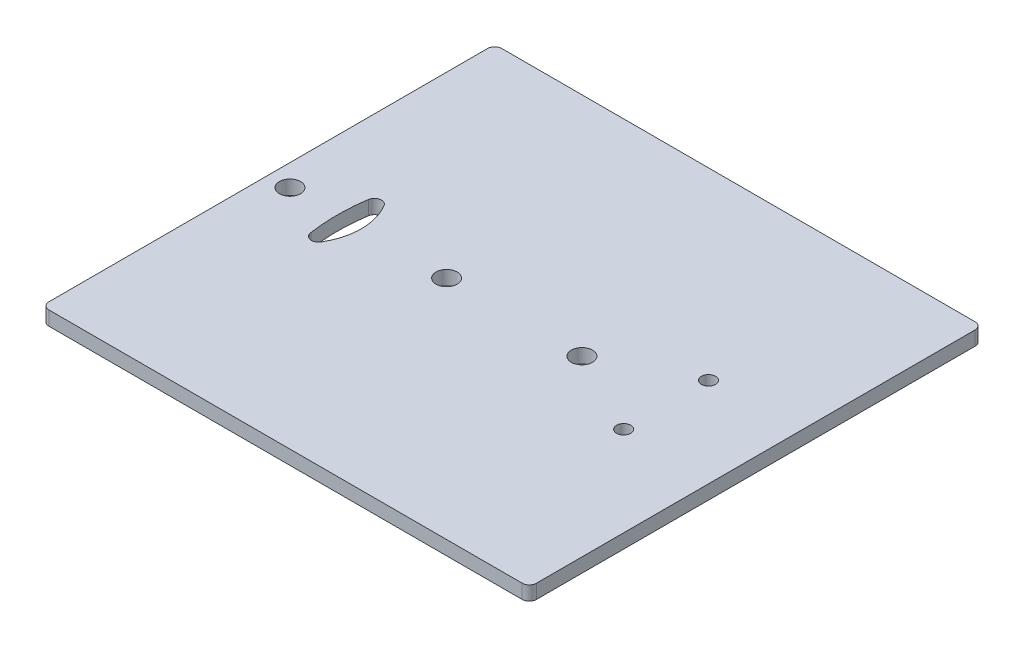
from build123d import *

# Parameters (mm, degrees)
CROQUIS1_W              = 69
CROQUIS1_H              = 64.099232263
CROQUIS1_R              = 1
CROQUIS1_R_2            = 1.5
SALIENTE_EXTRUIR1_DEPTH = 2
REDONDEO1_R             = 1


with BuildPart() as part:
    # Croquis1 → Saliente-Extruir1 (new body)
    with BuildSketch(Plane(origin=(0, 0, 0), x_dir=(1, 0, 0), z_dir=(0, 1, 0))):
        with Locations((-35.029110392, 0.70962906)):
            Rectangle(CROQUIS1_W, CROQUIS1_H)
        with BuildLine():
            ThreePointArc((-59.454384172, 4.810651437), (-58.662459069, 5.641041677), (-57.611472837, 5.180475439))
            ThreePointArc((-57.611472837, 5.180475439), (-56.358108465, 0.762709988), (-57.556841461, -3.67019121))
            ThreePointArc((-57.556841461, -3.67019121), (-57.60722938, -3.763799887), (-57.667223738, -3.851562088))
            ThreePointArc((-57.667223738, -3.851562088), (-58.665645829, -4.226208068), (-59.438939328, -3.491889713))
            ThreePointArc((-59.438939328, -3.491889713), (-59.459295474, -3.392138765), (-59.469455013, -3.290840157))
            ThreePointArc((-59.469455013, -3.290840157), (-59.763795222, 0.760467206), (-59.454384172, 4.810651437))
        make_face(mode=Mode.SUBTRACT)
        with Locations((-13.221985845, -5.290370941)):
            Circle(CROQUIS1_R, mode=Mode.SUBTRACT)
        with Locations((-66.45759178, 0.709629059)):
            Circle(CROQUIS1_R_2, mode=Mode.SUBTRACT)
        with Locations((-44.286593268, 0.709629059)):
            Circle(CROQUIS1_R_2, mode=Mode.SUBTRACT)
        with Locations((-25.130085357, 0.709629059)):
            Circle(CROQUIS1_R_2, mode=Mode.SUBTRACT)
        with Locations((-13.221985845, 6.709629059)):
            Circle(CROQUIS1_R, mode=Mode.SUBTRACT)
    extrude(amount=SALIENTE_EXTRUIR1_DEPTH)

    # Redondeo1
    redondeo1_edges = [part.edges().sort_by_distance(p)[0] for p in [
        (-0.529110392, 1, 31.339987072),
        (-69.529110392, 1, 31.339987072),
        (-69.529110392, 1, -32.759245191),
        (-0.529110392, 1, -32.759245191),
    ]]
    fillet(redondeo1_edges, radius=REDONDEO1_R)


solid = part.part
